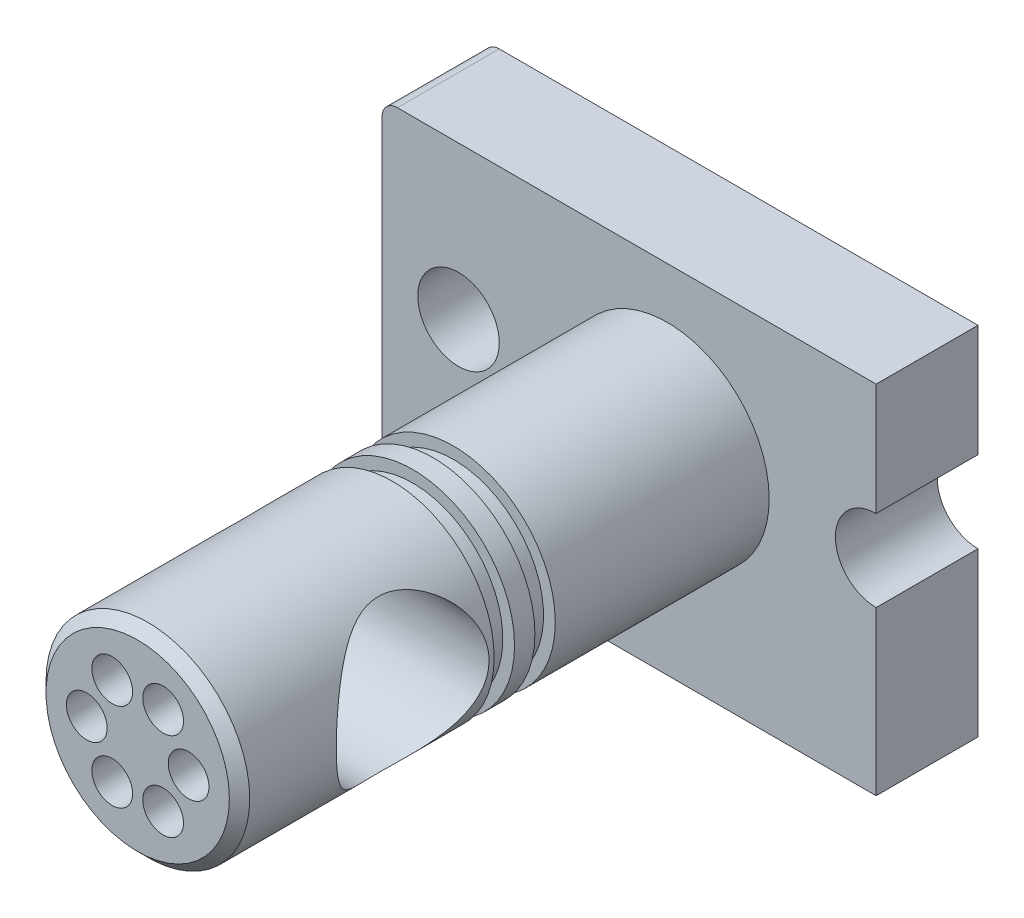
from build123d import *

# Parameters (mm, degrees)
SKETCH1_R               = 8
BOSS_EXTRUDE1_DEPTH     = 20
SKETCH2_R               = 20
BOSS_EXTRUDE2_DEPTH     = 104
SKETCH3_R               = 15
CUT_EXTRUDE1_DEPTH      = 42
CUT_EXTRUDE1_DEPTH_BACK = 57
SKETCH4_W               = 4
SKETCH4_H               = 2.3
SKETCH5_R               = 4
CUT_EXTRUDE2_DEPTH      = 30
CIRPATTERN1_COUNT       = 6
FILLET1_R               = 3
CHAMFER1_SIZE           = 2


with BuildPart() as part:
    # Sketch1 → Boss-Extrude1 (new body)
    with BuildSketch(Plane.XY):
        with BuildLine():
            Line((41, -8), (41, -40))
            Line((41, -40), (-56, -40))
            Line((-56, -40), (-56, 30))
            Line((-56, 30), (41, 30))
            Line((41, 30), (41, 8))
            ThreePointArc((41, 8), (33, 0), (41, -8))
        make_face()
        with Locations((-41, 0)):
            Circle(SKETCH1_R, mode=Mode.SUBTRACT)
    extrude(amount=BOSS_EXTRUDE1_DEPTH)

    # Sketch2 → Boss-Extrude2 (add)
    with BuildSketch(Plane.XY.offset(20)):
        Circle(SKETCH2_R)
    extrude(amount=BOSS_EXTRUDE2_DEPTH)

    # Sketch3 → Cut-Extrude1 (cut, two sides)
    with BuildSketch(Plane(origin=(0, 0, 0), x_dir=(0, 0, -1), z_dir=(1, 0, 0))) as cut_extrude1_sk:
        with Locations((-90, 0)):
            Circle(SKETCH3_R)
    extrude(amount=CUT_EXTRUDE1_DEPTH, mode=Mode.SUBTRACT)
    extrude(cut_extrude1_sk.sketch, amount=-CUT_EXTRUDE1_DEPTH_BACK, mode=Mode.SUBTRACT)

    # Sketch4 → Cut-Revolve1 (revolve, cut)
    with BuildSketch(Plane(origin=(0, 0, 0), x_dir=(0, 0, -1), z_dir=(1, 0, 0))):
        with Locations((-72, 18.85)):
            Rectangle(SKETCH4_W, SKETCH4_H)
        with Locations((-64, 18.85)):
            Rectangle(SKETCH4_W, SKETCH4_H)
    revolve(axis=Axis((0, 0, 0), (0, 0, 1)), mode=Mode.SUBTRACT)

    # Sketch5 → Cut-Extrude2 (cut)
    with BuildSketch(Plane.XY.offset(124)):
        with Locations((10, 0)):
            Circle(SKETCH5_R)
    cut_extrude2 = extrude(amount=-CUT_EXTRUDE2_DEPTH, mode=Mode.SUBTRACT)

    # CirPattern1: Cut-Extrude2 ×6 about axis
    cirpattern1_axis = Axis((0, 0, 0), (0, 0, 1))
    for i in range(1, CIRPATTERN1_COUNT):
        add(cut_extrude2.rotate(cirpattern1_axis, i * 360 / CIRPATTERN1_COUNT), mode=Mode.SUBTRACT)

    # Fillet1
    fillet1_edges = [part.edges().sort_by_distance(p)[0] for p in [
        (-56, -40, 10),
        (-56, 30, 10),
    ]]
    fillet(fillet1_edges, radius=FILLET1_R)

    # Chamfer1
    chamfer1_edges = [part.edges().sort_by_distance(p)[0] for p in [
        (-20, 0, 124),
    ]]
    chamfer(chamfer1_edges, length=CHAMFER1_SIZE)


solid = part.part
